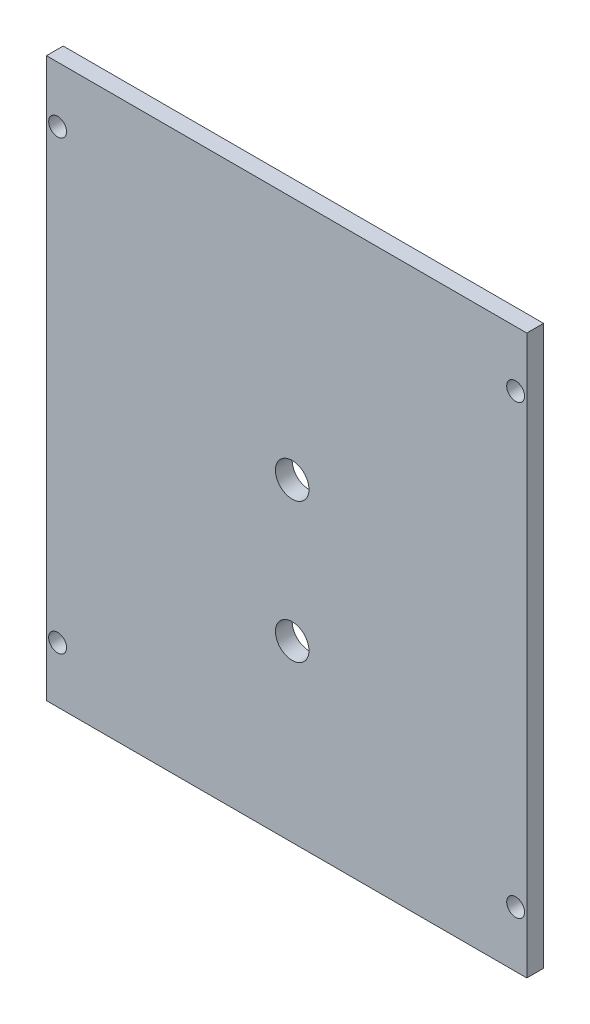
from build123d import *

# Parameters (mm, degrees)
SKETCH_1_W          = 84
SKETCH_1_H          = 100
EXTRUDE_1_DEPTH     = 3
SKETCH_3_R          = 3
CUT_EXTRUDE_1_DEPTH = 3
SKETCH_4_W          = 3
SKETCH_4_H          = 100
EXTRUDE_2_DEPTH     = 2
SKETCH_5_R          = 1.6
CUT_EXTRUDE_2_DEPTH = 4


with BuildPart() as part:
    # 草图1 → 凸台-拉伸1 (new body)
    with BuildSketch(Plane.XY):
        with Locations((42, 50)):
            Rectangle(SKETCH_1_W, SKETCH_1_H)
    extrude(amount=EXTRUDE_1_DEPTH)

    # 草图3 → 切除-拉伸1 (cut)
    with BuildSketch(Plane.XY.offset(3)):
        with Locations((42, 31.24)):
            Circle(SKETCH_3_R)
        with Locations((42, 56.24)):
            Circle(SKETCH_3_R)
    extrude(amount=-CUT_EXTRUDE_1_DEPTH, mode=Mode.SUBTRACT)

    # 草图4 → 凸台-拉伸2 (add)
    with BuildSketch(Plane.ZY):
        with Locations((1.5, 50)):
            Rectangle(SKETCH_4_W, SKETCH_4_H)
    extrude(amount=EXTRUDE_2_DEPTH)

    # 草图5 → 切除-拉伸2 (cut, through all)
    with BuildSketch(Plane.XY.offset(3)):
        with Locations((82, 10)):
            Circle(SKETCH_5_R)
        with Locations((82, 90)):
            Circle(SKETCH_5_R)
        with Locations((0, 90)):
            Circle(SKETCH_5_R)
        with Locations((0, 10)):
            Circle(SKETCH_5_R)
    extrude(amount=-CUT_EXTRUDE_2_DEPTH, mode=Mode.SUBTRACT)


solid = part.part
